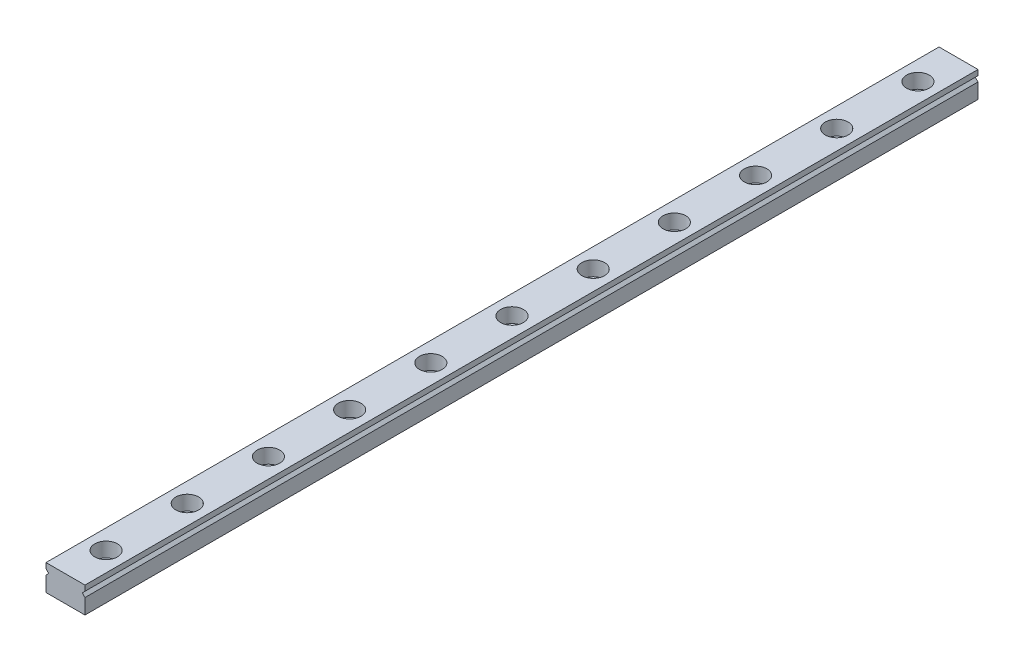
from build123d import *

# Parameters (mm, degrees)
BOSS_EXTRUDE1_DEPTH = 275
SKETCH2_R           = 2.5
CUT_EXTRUDE1_DEPTH  = 9
SKETCH2_3_R         = 3.5
SKETCH2_3_R_2       = 2.5
CUT_EXTRUDE2_DEPTH  = 4.5


with BuildPart() as part:
    # Sketch1 → Boss-Extrude1 (new body)
    with BuildSketch(Plane.XY):
        Polygon((6, -3), (6, 1.666666667), (5.166666667, 2.5), (6, 3.333333333), (6, 5), (-6, 5), (-6, 3.333333333), (-5.166666667, 2.5), (-6, 1.666666667), (-6, -3), align=None)
    extrude(amount=BOSS_EXTRUDE1_DEPTH)

    # Sketch2 → Cut-Extrude1 (cut, through all)
    with BuildSketch(Plane(origin=(0, 5, 0), x_dir=(1, 0, 0), z_dir=(0, 1, 0))):
        with Locations((0, -12.5)):
            Circle(SKETCH2_R)
        with Locations((0, -262.5)):
            Circle(SKETCH2_R)
        with Locations((0, -137.5)):
            Circle(SKETCH2_R)
        with Locations((0, -37.5)):
            Circle(SKETCH2_R)
        with Locations((0, -62.5)):
            Circle(SKETCH2_R)
        with Locations((0, -87.5)):
            Circle(SKETCH2_R)
        with Locations((0, -112.5)):
            Circle(SKETCH2_R)
        with Locations((0, -162.5)):
            Circle(SKETCH2_R)
        with Locations((0, -187.5)):
            Circle(SKETCH2_R)
        with Locations((0, -212.5)):
            Circle(SKETCH2_R)
        with Locations((0, -237.5)):
            Circle(SKETCH2_R)
    extrude(amount=-CUT_EXTRUDE1_DEPTH, mode=Mode.SUBTRACT)

    # Sketch2_3 → Cut-Extrude2 (cut)
    with BuildSketch(Plane(origin=(0, 5, 0), x_dir=(1, 0, 0), z_dir=(0, 1, 0))):
        with Locations((0, -12.5)):
            Circle(SKETCH2_3_R)
        with Locations((0, -12.5)):
            Circle(SKETCH2_3_R_2, mode=Mode.SUBTRACT)
        with Locations((0, -262.5)):
            Circle(SKETCH2_3_R)
        with Locations((0, -262.5)):
            Circle(SKETCH2_3_R_2, mode=Mode.SUBTRACT)
        with Locations((0, -137.5)):
            Circle(SKETCH2_3_R)
        with Locations((0, -137.5)):
            Circle(SKETCH2_3_R_2, mode=Mode.SUBTRACT)
        with Locations((0, -37.5)):
            Circle(SKETCH2_3_R)
        with Locations((0, -37.5)):
            Circle(SKETCH2_3_R_2, mode=Mode.SUBTRACT)
        with Locations((0, -62.5)):
            Circle(SKETCH2_3_R)
        with Locations((0, -62.5)):
            Circle(SKETCH2_3_R_2, mode=Mode.SUBTRACT)
        with Locations((0, -87.5)):
            Circle(SKETCH2_3_R)
        with Locations((0, -87.5)):
            Circle(SKETCH2_3_R_2, mode=Mode.SUBTRACT)
        with Locations((0, -112.5)):
            Circle(SKETCH2_3_R)
        with Locations((0, -112.5)):
            Circle(SKETCH2_3_R_2, mode=Mode.SUBTRACT)
        with Locations((0, -162.5)):
            Circle(SKETCH2_3_R)
        with Locations((0, -162.5)):
            Circle(SKETCH2_3_R_2, mode=Mode.SUBTRACT)
        with Locations((0, -187.5)):
            Circle(SKETCH2_3_R)
        with Locations((0, -187.5)):
            Circle(SKETCH2_3_R_2, mode=Mode.SUBTRACT)
        with Locations((0, -212.5)):
            Circle(SKETCH2_3_R)
        with Locations((0, -212.5)):
            Circle(SKETCH2_3_R_2, mode=Mode.SUBTRACT)
        with Locations((0, -237.5)):
            Circle(SKETCH2_3_R)
        with Locations((0, -237.5)):
            Circle(SKETCH2_3_R_2, mode=Mode.SUBTRACT)
    extrude(amount=-CUT_EXTRUDE2_DEPTH, mode=Mode.SUBTRACT)


solid = part.part
